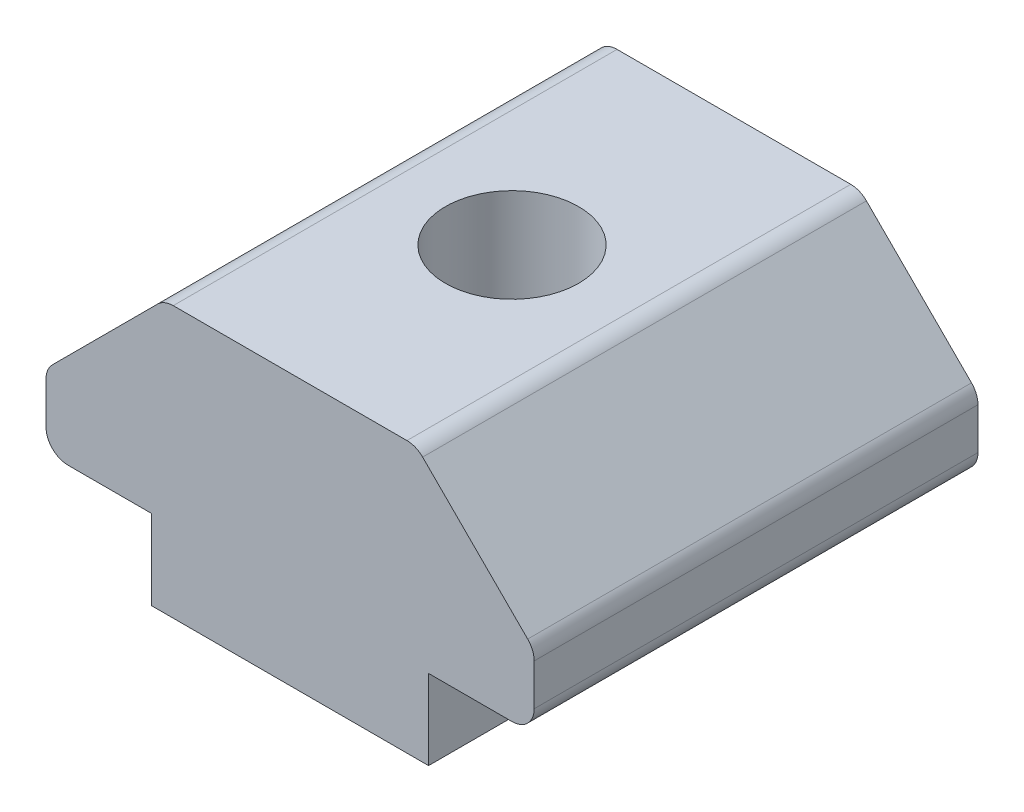
from build123d import *

# Parameters (mm, degrees)
SALIENTE_EXTRUIR1_DEPTH    = 10
REDONDEO1_R                = 0.5
REDONDEO2_R                = 0.5
CROQUIS3_W                 = 6.24
CROQUIS3_H                 = 1.8
SALIENTE_EXTRUIR2_DEPTH    = 10
CROQUIS2_R                 = 1.5
CORTAR_EXTRUIR1_DEPTH      = 2.8
CORTAR_EXTRUIR1_DEPTH_BACK = 5.3


with BuildPart() as part:
    # Croquis1 → Saliente-Extruir1 (new body)
    with BuildSketch(Plane(origin=(0, 0, 0), x_dir=(-1, 0, 0), z_dir=(0, 0, 1))):
        Polygon((4.5, -1.799339828), (4.5, -3.439339828), (7.16, -6.099339828), (9.75, -6.099339828), (12.84, -6.099339828), (15.5, -3.439339828), (15.5, -1.799339828), align=None)
    extrude(amount=SALIENTE_EXTRUIR1_DEPTH)

    # Redondeo1
    redondeo1_edges = [part.edges().sort_by_distance(p)[0] for p in [
        (-15.5, 1.799339828, 5),
    ]]
    fillet(redondeo1_edges, radius=REDONDEO1_R)

    # Redondeo2
    redondeo2_edges = [part.edges().sort_by_distance(p)[0] for p in [
        (-15.5, 3.439339828, 5),
        (-12.84, 6.099339828, 5),
        (-7.16, 6.099339828, 5),
        (-4.5, 3.439339828, 5),
        (-4.5, 1.799339828, 5),
    ]]
    fillet(redondeo2_edges, radius=REDONDEO2_R)

    # Croquis3 → Saliente-Extruir2 (add)
    with BuildSketch(Plane.XY.offset(10)):
        with Locations((-10, 0.899339828)):
            Rectangle(CROQUIS3_W, CROQUIS3_H)
    extrude(amount=-SALIENTE_EXTRUIR2_DEPTH)

    # Croquis2 → Cortar-Extruir1 (cut, two sides)
    with BuildSketch(Plane(origin=(0, 1.799339828, 0), x_dir=(-1, 0, 0), z_dir=(0, -1, 0))) as cortar_extruir1_sk:
        with Locations((10, -5)):
            Circle(CROQUIS2_R)
    extrude(amount=CORTAR_EXTRUIR1_DEPTH, mode=Mode.SUBTRACT)
    extrude(cortar_extruir1_sk.sketch, amount=-CORTAR_EXTRUIR1_DEPTH_BACK, mode=Mode.SUBTRACT)


solid = part.part
